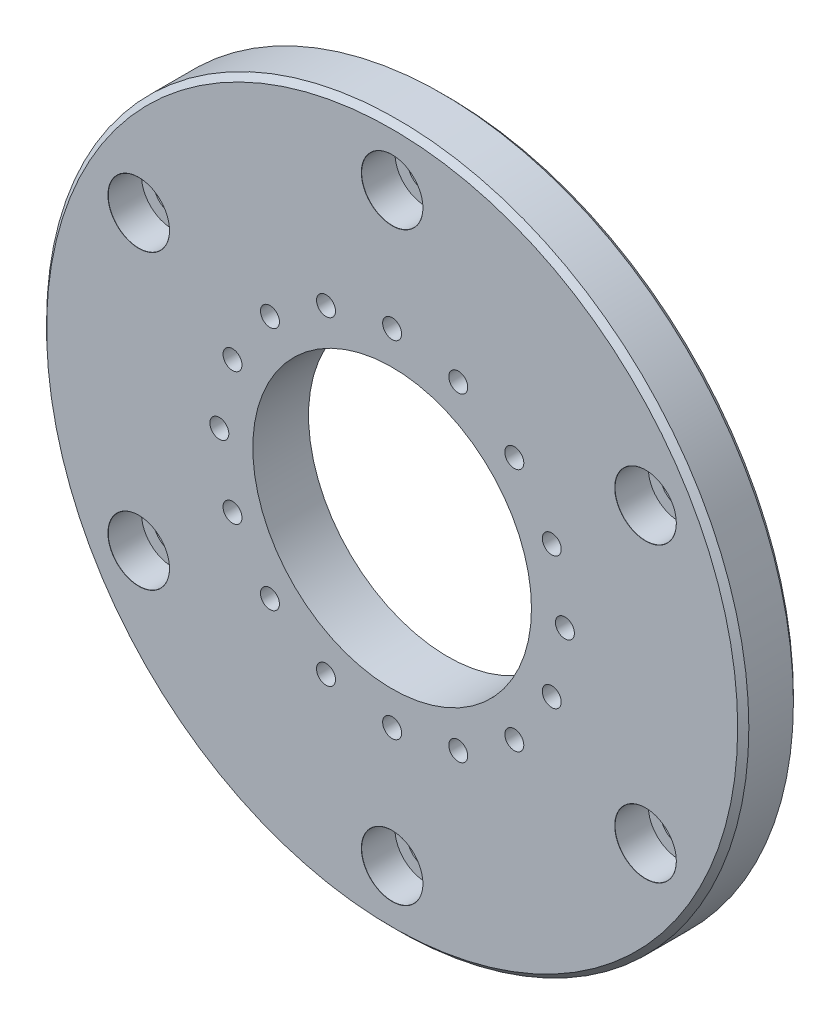
from build123d import *

# Parameters (mm, degrees)
SKETCH2_R                                      = 63
BOSS_EXTRUDE1_DEPTH                            = 10
SKETCH4_R                                      = 25
CUT_EXTRUDE1_DEPTH                             = 11
CIRPATTERN1_COUNT                              = 6
CBORE_FOR_M3_SOCKET_HEAD_CAP_SCREW2_AT_2_COUNT = 2
CBORE_FOR_M3_SOCKET_HEAD_CAP_SCREW2_AT_2_PITCH = 12.095599965
CBORE_FOR_M3_SOCKET_HEAD_CAP_SCREW2_AT_3_COUNT = 2
CBORE_FOR_M3_SOCKET_HEAD_CAP_SCREW2_AT_3_PITCH = 23.726372807
CBORE_FOR_M3_SOCKET_HEAD_CAP_SCREW2_AT_4_COUNT = 2
CBORE_FOR_M3_SOCKET_HEAD_CAP_SCREW2_AT_4_PITCH = 34.445354447
CBORE_FOR_M3_SOCKET_HEAD_CAP_SCREW2_AT_5_COUNT = 2
CBORE_FOR_M3_SOCKET_HEAD_CAP_SCREW2_AT_5_PITCH = 43.840620434
CBORE_FOR_M3_SOCKET_HEAD_CAP_SCREW2_AT_6_COUNT = 2
CBORE_FOR_M3_SOCKET_HEAD_CAP_SCREW2_AT_6_PITCH = 51.551115963
CBORE_FOR_M3_SOCKET_HEAD_CAP_SCREW2_AT_7_COUNT = 2
CBORE_FOR_M3_SOCKET_HEAD_CAP_SCREW2_AT_7_PITCH = 57.280531016
CBORE_FOR_M3_SOCKET_HEAD_CAP_SCREW2_AT_8_COUNT = 2
CBORE_FOR_M3_SOCKET_HEAD_CAP_SCREW2_AT_8_PITCH = 60.808687385
CBORE_FOR_M3_SOCKET_HEAD_CAP_SCREW2_AT_9_COUNT = 2
CBORE_FOR_M3_SOCKET_HEAD_CAP_SCREW2_AT_9_PITCH = 62
CBORE_FOR_M3_SOCKET_HEAD_CAP_SCREW2_AT_1_COUNT = 2
CBORE_FOR_M3_SOCKET_HEAD_CAP_SCREW2_AT_1_PITCH = 60.808687385
CBORE_FOR_M3_SOCKET_HEAD_CAP_SCREW2_2_COUNT    = 2
CBORE_FOR_M3_SOCKET_HEAD_CAP_SCREW2_2_PITCH    = 57.280531016
CBORE_FOR_M3_SOCKET_HEAD_CAP_SCREW2_3_COUNT    = 2
CBORE_FOR_M3_SOCKET_HEAD_CAP_SCREW2_3_PITCH    = 51.551115963
CBORE_FOR_M3_SOCKET_HEAD_CAP_SCREW2_4_COUNT    = 2
CBORE_FOR_M3_SOCKET_HEAD_CAP_SCREW2_4_PITCH    = 43.840620434
CBORE_FOR_M3_SOCKET_HEAD_CAP_SCREW2_5_COUNT    = 2
CBORE_FOR_M3_SOCKET_HEAD_CAP_SCREW2_5_PITCH    = 34.445354447
CBORE_FOR_M3_SOCKET_HEAD_CAP_SCREW2_6_COUNT    = 2
CBORE_FOR_M3_SOCKET_HEAD_CAP_SCREW2_6_PITCH    = 23.726372807
CBORE_FOR_M3_SOCKET_HEAD_CAP_SCREW2_7_COUNT    = 2
CBORE_FOR_M3_SOCKET_HEAD_CAP_SCREW2_7_PITCH    = 12.095599965
CHAMFER1_SIZE                                  = 1


with BuildPart() as part:
    # Sketch2 → Boss-Extrude1 (new body)
    with BuildSketch(Plane.XY):
        with Locations((-200, 0)):
            Circle(SKETCH2_R)
    extrude(amount=BOSS_EXTRUDE1_DEPTH)

    # Sketch4 → Cut-Extrude1 (cut, through all)
    with BuildSketch(Plane.XY.offset(10)):
        with Locations((-200, 0)):
            Circle(SKETCH4_R)
    extrude(amount=-CUT_EXTRUDE1_DEPTH, mode=Mode.SUBTRACT)

    # Sketch6 → CBORE for M8 Socket Head Cap Screw1 (revolve, cut)
    with BuildSketch(Plane(origin=(-200, 52.5, 10), x_dir=(0, -1, 0), z_dir=(1, 0, 0))):
        Polygon((0, 0), (0, 19), (3.3, 17.017159957), (3.3, 6), (5.5, 6), (5.5, 0.025), (5.525, 0), align=None)
    cbore_for_m8_socket_head_cap_screw1 = revolve(axis=Axis((-200, 52.5, 16.35), (0, 0, -1)), mode=Mode.SUBTRACT)

    # CirPattern1: CBORE for M8 Socket Head Cap Screw1 ×6 about axis
    cirpattern1_axis = Axis((-200, 0, 0), (0, 0, 1))
    for i in range(1, CIRPATTERN1_COUNT):
        add(cbore_for_m8_socket_head_cap_screw1.rotate(cirpattern1_axis, i * 360 / CIRPATTERN1_COUNT), mode=Mode.SUBTRACT)

    # Sketch11 → CBORE for M3 Socket Head Cap Screw2 (revolve, cut)
    with BuildSketch(Plane(origin=(-200, 31, 0), x_dir=(0, 1, 0), z_dir=(1, 0, 0))):
        Polygon((0, 0), (0, 10), (1.7, 10), (1.7, 3), (3.25, 3), (3.25, 0.025), (3.275, 0), align=None)
    cbore_for_m3_socket_head_cap_screw2 = revolve(axis=Axis((-200, 31, -6.35), (0, 0, 1)), mode=Mode.SUBTRACT)

    # CBORE for M3 Socket Head Cap Screw2 at 2: CBORE for M3 Socket Head Cap Screw2 ×2
    with Locations(*[Vector(0.98078528, -0.195090322, 0) * (i * CBORE_FOR_M3_SOCKET_HEAD_CAP_SCREW2_AT_2_PITCH) for i in range(1, CBORE_FOR_M3_SOCKET_HEAD_CAP_SCREW2_AT_2_COUNT)]):
        add(cbore_for_m3_socket_head_cap_screw2, mode=Mode.SUBTRACT)

    # CBORE for M3 Socket Head Cap Screw2 at 3: CBORE for M3 Socket Head Cap Screw2 ×2
    with Locations(*[Vector(0.923879533, -0.382683432, 0) * (i * CBORE_FOR_M3_SOCKET_HEAD_CAP_SCREW2_AT_3_PITCH) for i in range(1, CBORE_FOR_M3_SOCKET_HEAD_CAP_SCREW2_AT_3_COUNT)]):
        add(cbore_for_m3_socket_head_cap_screw2, mode=Mode.SUBTRACT)

    # CBORE for M3 Socket Head Cap Screw2 at 4: CBORE for M3 Socket Head Cap Screw2 ×2
    with Locations(*[Vector(0.831469612, -0.555570233, 0) * (i * CBORE_FOR_M3_SOCKET_HEAD_CAP_SCREW2_AT_4_PITCH) for i in range(1, CBORE_FOR_M3_SOCKET_HEAD_CAP_SCREW2_AT_4_COUNT)]):
        add(cbore_for_m3_socket_head_cap_screw2, mode=Mode.SUBTRACT)

    # CBORE for M3 Socket Head Cap Screw2 at 5: CBORE for M3 Socket Head Cap Screw2 ×2
    with Locations(*[Vector(0.707106781, -0.707106781, 0) * (i * CBORE_FOR_M3_SOCKET_HEAD_CAP_SCREW2_AT_5_PITCH) for i in range(1, CBORE_FOR_M3_SOCKET_HEAD_CAP_SCREW2_AT_5_COUNT)]):
        add(cbore_for_m3_socket_head_cap_screw2, mode=Mode.SUBTRACT)

    # CBORE for M3 Socket Head Cap Screw2 at 6: CBORE for M3 Socket Head Cap Screw2 ×2
    with Locations(*[Vector(0.555570233, -0.831469612, 0) * (i * CBORE_FOR_M3_SOCKET_HEAD_CAP_SCREW2_AT_6_PITCH) for i in range(1, CBORE_FOR_M3_SOCKET_HEAD_CAP_SCREW2_AT_6_COUNT)]):
        add(cbore_for_m3_socket_head_cap_screw2, mode=Mode.SUBTRACT)

    # CBORE for M3 Socket Head Cap Screw2 at 7: CBORE for M3 Socket Head Cap Screw2 ×2
    with Locations(*[Vector(0.382683432, -0.923879533, 0) * (i * CBORE_FOR_M3_SOCKET_HEAD_CAP_SCREW2_AT_7_PITCH) for i in range(1, CBORE_FOR_M3_SOCKET_HEAD_CAP_SCREW2_AT_7_COUNT)]):
        add(cbore_for_m3_socket_head_cap_screw2, mode=Mode.SUBTRACT)

    # CBORE for M3 Socket Head Cap Screw2 at 8: CBORE for M3 Socket Head Cap Screw2 ×2
    with Locations(*[Vector(0.195090322, -0.98078528, 0) * (i * CBORE_FOR_M3_SOCKET_HEAD_CAP_SCREW2_AT_8_PITCH) for i in range(1, CBORE_FOR_M3_SOCKET_HEAD_CAP_SCREW2_AT_8_COUNT)]):
        add(cbore_for_m3_socket_head_cap_screw2, mode=Mode.SUBTRACT)

    # CBORE for M3 Socket Head Cap Screw2 at 9: CBORE for M3 Socket Head Cap Screw2 ×2
    with Locations(*[(0, -i * CBORE_FOR_M3_SOCKET_HEAD_CAP_SCREW2_AT_9_PITCH, 0) for i in range(1, CBORE_FOR_M3_SOCKET_HEAD_CAP_SCREW2_AT_9_COUNT)]):
        add(cbore_for_m3_socket_head_cap_screw2, mode=Mode.SUBTRACT)

    # CBORE for M3 Socket Head Cap Screw2 at 1: CBORE for M3 Socket Head Cap Screw2 ×2
    with Locations(*[Vector(-0.195090322, -0.98078528, 0) * (i * CBORE_FOR_M3_SOCKET_HEAD_CAP_SCREW2_AT_1_PITCH) for i in range(1, CBORE_FOR_M3_SOCKET_HEAD_CAP_SCREW2_AT_1_COUNT)]):
        add(cbore_for_m3_socket_head_cap_screw2, mode=Mode.SUBTRACT)

    # CBORE for M3 Socket Head Cap Screw2  2: CBORE for M3 Socket Head Cap Screw2 ×2
    with Locations(*[Vector(-0.382683432, -0.923879533, 0) * (i * CBORE_FOR_M3_SOCKET_HEAD_CAP_SCREW2_2_PITCH) for i in range(1, CBORE_FOR_M3_SOCKET_HEAD_CAP_SCREW2_2_COUNT)]):
        add(cbore_for_m3_socket_head_cap_screw2, mode=Mode.SUBTRACT)

    # CBORE for M3 Socket Head Cap Screw2  3: CBORE for M3 Socket Head Cap Screw2 ×2
    with Locations(*[Vector(-0.555570233, -0.831469612, 0) * (i * CBORE_FOR_M3_SOCKET_HEAD_CAP_SCREW2_3_PITCH) for i in range(1, CBORE_FOR_M3_SOCKET_HEAD_CAP_SCREW2_3_COUNT)]):
        add(cbore_for_m3_socket_head_cap_screw2, mode=Mode.SUBTRACT)

    # CBORE for M3 Socket Head Cap Screw2  4: CBORE for M3 Socket Head Cap Screw2 ×2
    with Locations(*[Vector(-0.707106781, -0.707106781, 0) * (i * CBORE_FOR_M3_SOCKET_HEAD_CAP_SCREW2_4_PITCH) for i in range(1, CBORE_FOR_M3_SOCKET_HEAD_CAP_SCREW2_4_COUNT)]):
        add(cbore_for_m3_socket_head_cap_screw2, mode=Mode.SUBTRACT)

    # CBORE for M3 Socket Head Cap Screw2  5: CBORE for M3 Socket Head Cap Screw2 ×2
    with Locations(*[Vector(-0.831469612, -0.555570233, 0) * (i * CBORE_FOR_M3_SOCKET_HEAD_CAP_SCREW2_5_PITCH) for i in range(1, CBORE_FOR_M3_SOCKET_HEAD_CAP_SCREW2_5_COUNT)]):
        add(cbore_for_m3_socket_head_cap_screw2, mode=Mode.SUBTRACT)

    # CBORE for M3 Socket Head Cap Screw2  6: CBORE for M3 Socket Head Cap Screw2 ×2
    with Locations(*[Vector(-0.923879533, -0.382683432, 0) * (i * CBORE_FOR_M3_SOCKET_HEAD_CAP_SCREW2_6_PITCH) for i in range(1, CBORE_FOR_M3_SOCKET_HEAD_CAP_SCREW2_6_COUNT)]):
        add(cbore_for_m3_socket_head_cap_screw2, mode=Mode.SUBTRACT)

    # CBORE for M3 Socket Head Cap Screw2  7: CBORE for M3 Socket Head Cap Screw2 ×2
    with Locations(*[Vector(-0.98078528, -0.195090322, 0) * (i * CBORE_FOR_M3_SOCKET_HEAD_CAP_SCREW2_7_PITCH) for i in range(1, CBORE_FOR_M3_SOCKET_HEAD_CAP_SCREW2_7_COUNT)]):
        add(cbore_for_m3_socket_head_cap_screw2, mode=Mode.SUBTRACT)

    # Chamfer1
    chamfer1_edges = [part.edges().sort_by_distance(p)[0] for p in [
        (-263, 0, 0),
        (-263, 0, 10),
    ]]
    chamfer(chamfer1_edges, length=CHAMFER1_SIZE)


solid = part.part
